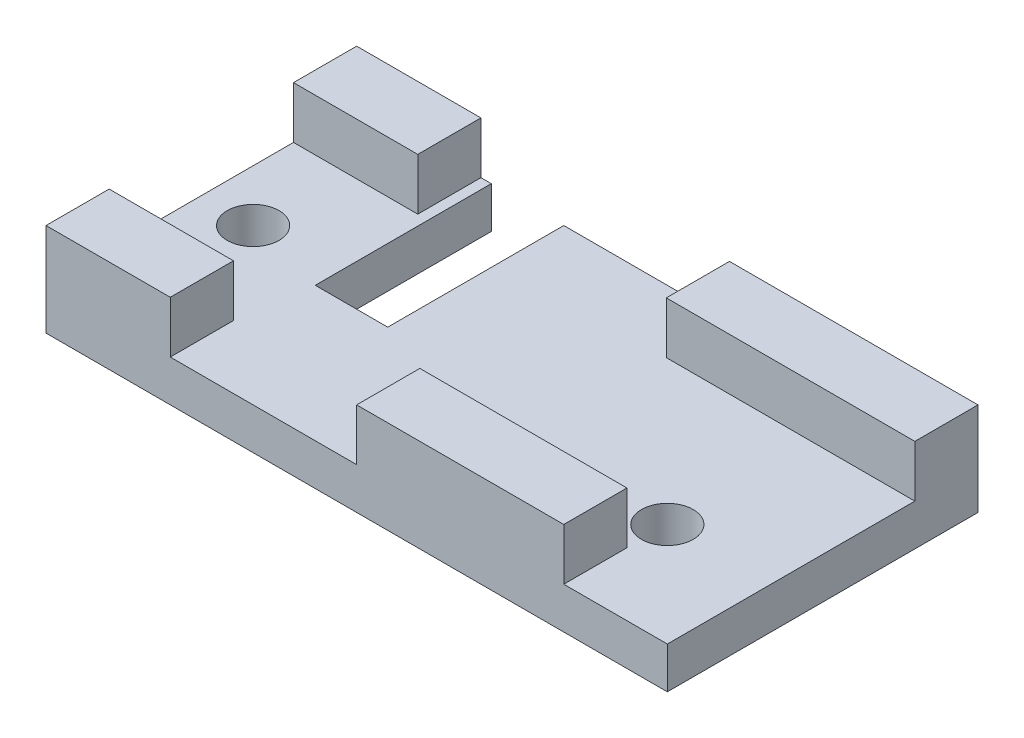
from build123d import *

# Parameters (mm, degrees)
SKETCH1_W           = 76.2
SKETCH1_H           = 38.1
BOSS_EXTRUDE1_DEPTH = 2.54
SKETCH2_W           = 15.24
SKETCH2_H           = 7.747
SKETCH2_W_2         = 30.48
SKETCH2_W_3         = 38.1
BOSS_EXTRUDE2_DEPTH = 6.35
SKETCH3_W           = 8.89
SKETCH3_H           = 21.59
CUT_EXTRUDE1_DEPTH  = 6.08
SKETCH4_W           = 12.7
SKETCH4_H           = 6.35
CUT_EXTRUDE2_DEPTH  = 7.747
SKETCH5_R           = 3.175
CUT_EXTRUDE3_DEPTH  = 12.43


with BuildPart() as part:
    # Sketch1 → Boss-Extrude1 (new body, symmetric)
    with BuildSketch(Plane(origin=(0, 0, 0), x_dir=(1, 0, 0), z_dir=(0, 1, 0))):
        Rectangle(SKETCH1_W, SKETCH1_H)
    extrude(amount=BOSS_EXTRUDE1_DEPTH, both=True)

    # Sketch2 → Boss-Extrude2 (add)
    with BuildSketch(Plane(origin=(0, 2.54, 0), x_dir=(1, 0, 0), z_dir=(0, 1, 0))):
        with Locations((-30.48, 15.1765)):
            Rectangle(SKETCH2_W, SKETCH2_H)
        with Locations((22.86, 15.1765)):
            Rectangle(SKETCH2_W_2, SKETCH2_H)
        with Locations((19.05, -15.1765)):
            Rectangle(SKETCH2_W_3, SKETCH2_H)
        with Locations((-30.48, -15.1765)):
            Rectangle(SKETCH2_W, SKETCH2_H)
    extrude(amount=BOSS_EXTRUDE2_DEPTH)

    # Sketch3 → Cut-Extrude1 (cut, through all)
    with BuildSketch(Plane(origin=(0, 2.54, 0), x_dir=(1, 0, 0), z_dir=(0, 1, 0))):
        with Locations((-17.145, 8.255)):
            Rectangle(SKETCH3_W, SKETCH3_H)
    extrude(amount=-CUT_EXTRUDE1_DEPTH, mode=Mode.SUBTRACT)

    # Sketch4 → Cut-Extrude2 (cut)
    with BuildSketch(Plane.XY.offset(19.05)):
        with Locations((31.75, 5.715)):
            Rectangle(SKETCH4_W, SKETCH4_H)
    extrude(amount=-CUT_EXTRUDE2_DEPTH, mode=Mode.SUBTRACT)

    # Sketch5 → Cut-Extrude3 (cut, through all)
    with BuildSketch(Plane.XZ.offset(2.54)):
        with Locations((25.4, 6.35)):
            Circle(SKETCH5_R)
        with Locations((-31.75, 0)):
            Circle(SKETCH5_R)
    extrude(amount=-CUT_EXTRUDE3_DEPTH, mode=Mode.SUBTRACT)


solid = part.part
